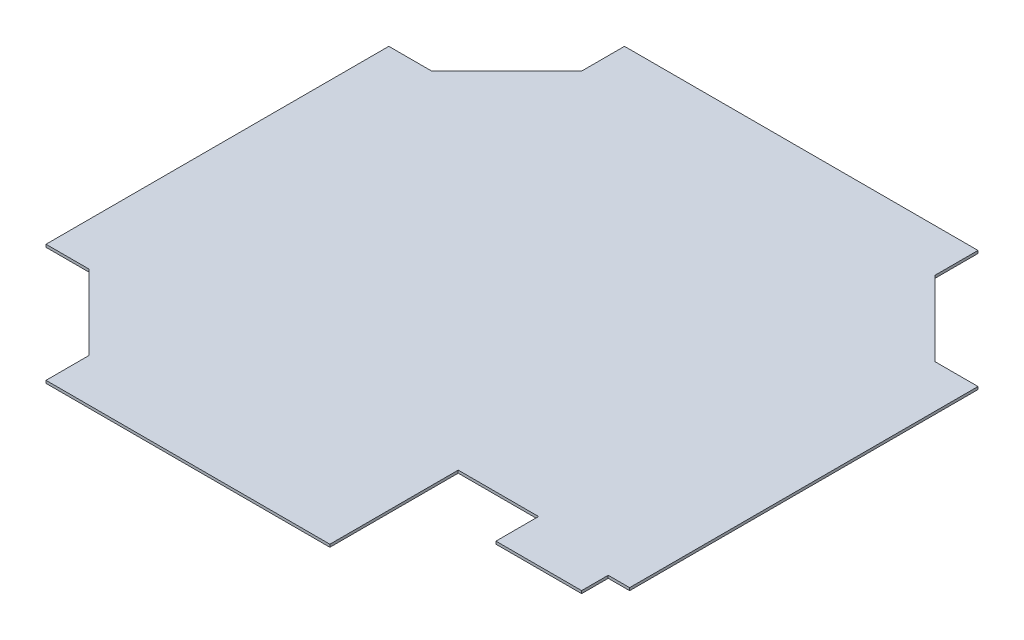
from build123d import *

# Parameters (mm, degrees)
SKETCH1_W           = 698.5
SKETCH1_H           = 685.8
BOSS_EXTRUDE1_DEPTH = 3.175
CUT_EXTRUDE1_DEPTH  = 4.175
CUT_EXTRUDE2_DEPTH  = 4.175


with BuildPart() as part:
    # Sketch1 → Boss-Extrude1 (new body)
    with BuildSketch(Plane(origin=(0, 0, 0), x_dir=(1, 0, 0), z_dir=(0, 1, 0))):
        Rectangle(SKETCH1_W, SKETCH1_H)
    extrude(amount=BOSS_EXTRUDE1_DEPTH)

    # Sketch3 → Cut-Extrude1 (cut, through all)
    with BuildSketch(Plane(origin=(0, 3.175, 0), x_dir=(1, 0, 0), z_dir=(0, 1, 0))):
        Polygon((-298.45, 203.2), (-209.55, 292.1), (-209.55, 342.9), (-349.25, 342.9), (-349.25, 203.2), align=None)
        Polygon((-349.25, -203.2), (-298.45, -203.2), (-209.55, -292.1), (-209.55, -342.9), (-349.25, -342.9), align=None)
        Polygon((349.25, 203.2), (298.45, 203.2), (209.55, 292.1), (209.55, 342.9), (349.25, 342.9), align=None)
    extrude(amount=-CUT_EXTRUDE1_DEPTH, mode=Mode.SUBTRACT)

    # Sketch7 → Cut-Extrude2 (cut, through all)
    with BuildSketch(Plane(origin=(-6.096, 3.175, 0.254), x_dir=(1, 0, 0), z_dir=(0, 1, 0))):
        Polygon((133.096, -190.5), (133.096, -355.346), (368.046, -355.346), (368.046, -209.55), (329.946, -209.55), (329.946, -241.046), (228.346, -241.046), (228.346, -190.5), align=None)
    extrude(amount=-CUT_EXTRUDE2_DEPTH, mode=Mode.SUBTRACT)


solid = part.part
